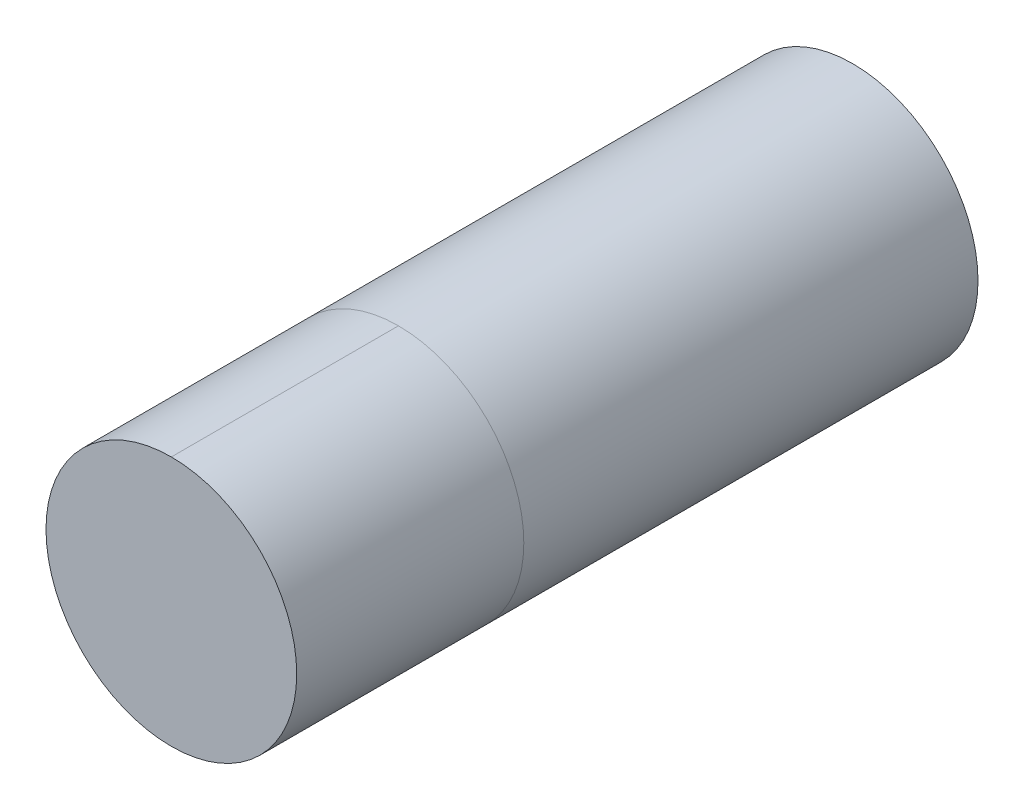
from build123d import *

# Parameters (mm, degrees)
SKETCH1_R           = 1.7526
BOSS_EXTRUDE1_DEPTH = 6.35
SKETCH2_R           = 1.7526
BOSS_EXTRUDE2_DEPTH = 3.175


with BuildPart() as part:
    # Sketch1 → Boss-Extrude1 (new body)
    with BuildSketch(Plane.XY):
        Circle(SKETCH1_R)
    extrude(amount=BOSS_EXTRUDE1_DEPTH)


with BuildPart() as body_2:
    # Sketch2 → Boss-Extrude2 (new body)
    with BuildSketch(Plane.XY.offset(6.35)):
        Circle(SKETCH2_R)
    extrude(amount=BOSS_EXTRUDE2_DEPTH)


solid = Compound([part.part, body_2.part])
